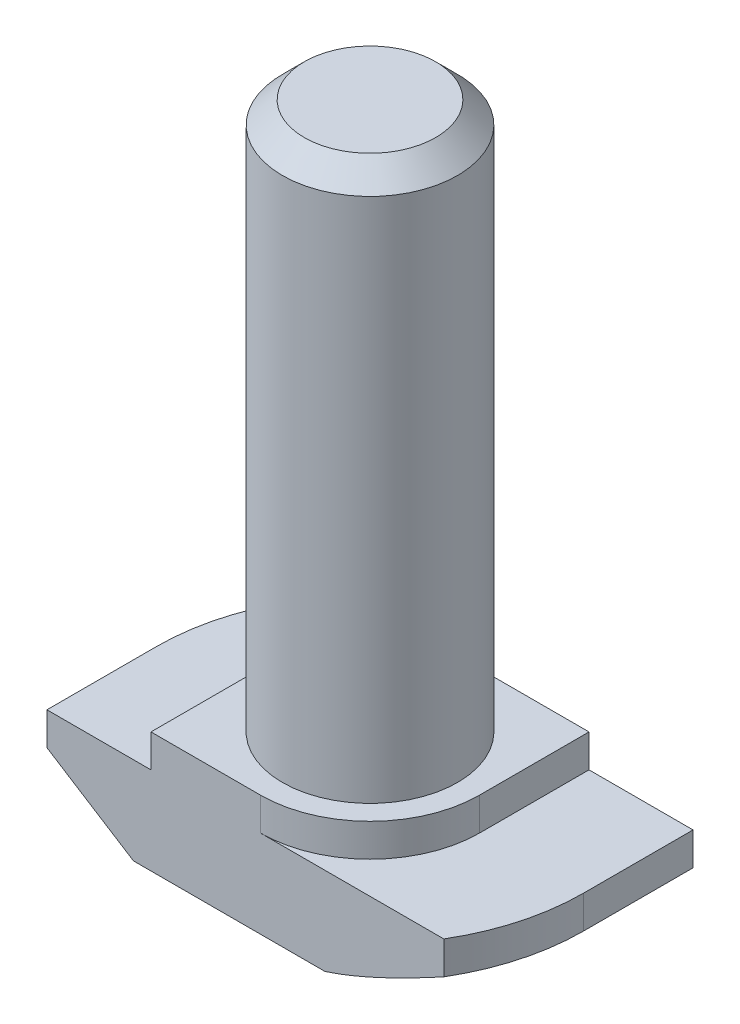
from build123d import *

# Parameters (mm, degrees)
EXTRUDE_1_DEPTH     = 5
CUT_EXTRUDE_1_DEPTH = 1.5
SKETCH_2_R          = 4
EXTRUDE_2_DEPTH     = 25
CUT_EXTRUDE_2_DEPTH = 5
CHAMFER_2_SIZE      = 1


with BuildPart() as part:
    # Эскиз1 → Бобышка-Вытянуть1 (new body, symmetric)
    with BuildSketch(Plane.XY):
        Polygon((9.75, 0), (-9.75, 0), (-9.75, 4), (-5, 4), (-5, 5.5), (5, 5.5), (5, 4), (9.75, 4), align=None)
    extrude(amount=EXTRUDE_1_DEPTH, both=True)

    # Эскиз3 → Вырез-Вытянуть1 (cut)
    with BuildSketch(Plane(origin=(0, 5.5, 0), x_dir=(1, 0, 0), z_dir=(0, 1, 0))):
        with BuildLine():
            Line((-5, 0), (-5, 5))
            Line((-5, 5), (0, 5))
            ThreePointArc((0, 5), (-3.535533906, 3.535533906), (-5, 0))
        make_face()
        with BuildLine():
            Line((0, -5), (5, -5))
            Line((5, -5), (5, 0))
            ThreePointArc((5, 0), (3.535533906, -3.535533906), (0, -5))
        make_face()
    extrude(amount=-CUT_EXTRUDE_1_DEPTH, mode=Mode.SUBTRACT)

    # Эскиз2 → Бобышка-Вытянуть2 (add)
    with BuildSketch(Plane(origin=(0, 5.5, 0), x_dir=(1, 0, 0), z_dir=(0, 1, 0))):
        with Locations(Location((0, 0, 0), (0, 0, 270))):  # turned: the seam where the file's is
            Circle(SKETCH_2_R)
    extrude(amount=EXTRUDE_2_DEPTH)

    # Эскиз4 → Вырез-Вытянуть2 (cut, through all)
    with BuildSketch(Plane(origin=(0, 4, 0), x_dir=(1, 0, 0), z_dir=(0, 1, 0))):
        with BuildLine():
            Line((-8.370334521, 5), (-9.75, 5))
            Line((-9.75, 5), (-9.75, 0))
            ThreePointArc((-9.75, 0), (-9.398756875, 2.59342808), (-8.370334521, 5))
        make_face()
        with BuildLine():
            Line((8.370334521, -5), (9.75, -5))
            Line((9.75, -5), (9.75, 0))
            ThreePointArc((9.75, 0), (9.398756875, -2.59342808), (8.370334521, -5))
        make_face()
    extrude(amount=-CUT_EXTRUDE_2_DEPTH, mode=Mode.SUBTRACT)

    # Вырез-По траектории1: sweep along a path in Эскиз6
    with BuildLine(Plane.XZ) as sweep_1_path:
        Line((0, -9.75), (9.75, -9.75))
        Line((9.75, -9.75), (9.75, 0))
        ThreePointArc((9.75, 0), (6.894291117, 6.894291117), (0, 9.75))
        Line((0, 9.75), (-9.75, 9.75))
        Line((-9.75, 9.75), (-9.75, 0))
        ThreePointArc((-9.75, 0), (-6.894291117, -6.894291117), (0, -9.75))
    # Эскиз5 → Вырез-По траектории1 (sweep, cut)
    with BuildSketch(Plane.XY.offset(5)):
        Polygon((-9.75, 2.5), (-5.8, 0), (-9.75, 0), align=None)
    sweep(path=sweep_1_path.line, transition=Transition.RIGHT, mode=Mode.SUBTRACT)

    # Фаска2
    chamfer_2_edges = [part.edges().sort_by_distance(p)[0] for p in [
        (0, 30.5, -4),
    ]]
    chamfer(chamfer_2_edges, length=CHAMFER_2_SIZE)


solid = part.part
